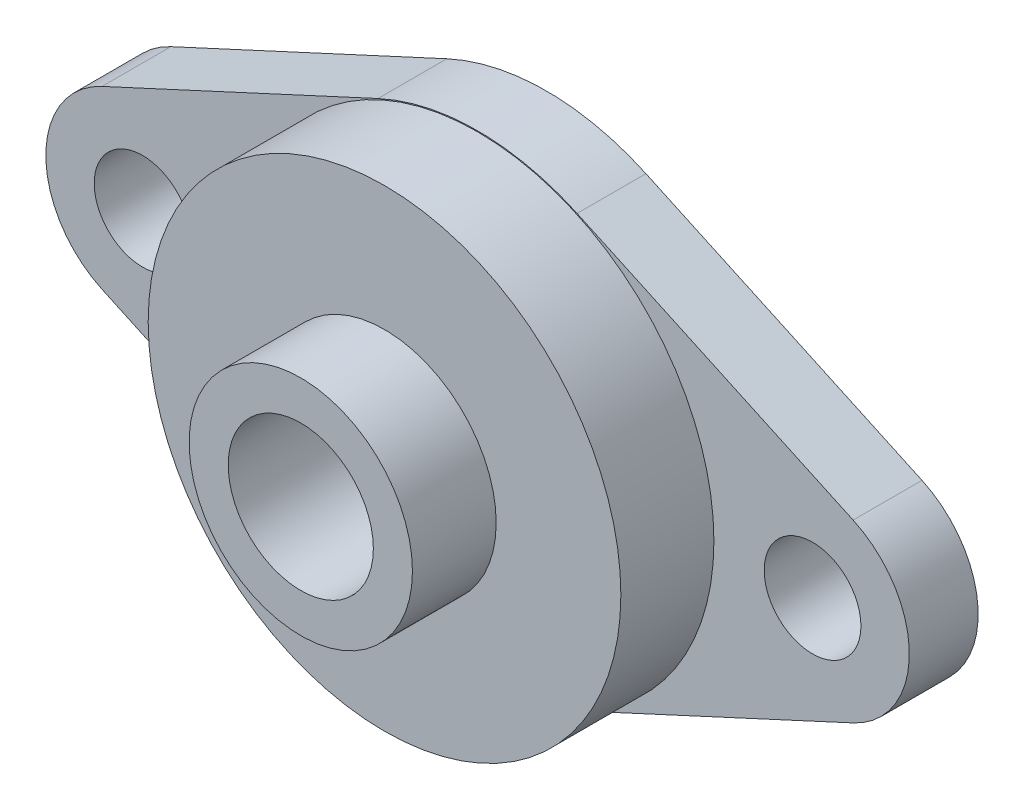
from build123d import *

# Parameters (mm, degrees)
SKETCH_2_R      = 2.6
SKETCH_2_R_2    = 3.9
EXTRUDE_1_DEPTH = 3.7
SKETCH_3_R      = 12.7
SKETCH_3_R_2    = 3.9
EXTRUDE_2_DEPTH = 5
SKETCH_4_R      = 6
SKETCH_4_R_2    = 3.9
EXTRUDE_3_DEPTH = 4.5


with BuildPart() as part:
    # 草圖2 → 填料-伸長1 (new body)
    with BuildSketch(Plane.XY):
        with BuildLine():
            Line((-20.181106134, 4.72046354), (-5.347916667, 11.574207849))
            ThreePointArc((-5.347916667, 11.574207849), (0, 12.75), (5.347916667, 11.574207849))
            Line((5.347916667, 11.574207849), (20.181106134, 4.72046354))
            ThreePointArc((20.181106134, 4.72046354), (23.2, 0), (20.181106134, -4.72046354))
            Line((20.181106134, -4.72046354), (5.347916667, -11.574207849))
            ThreePointArc((5.347916667, -11.574207849), (0, -12.75), (-5.347916667, -11.574207849))
            Line((-5.347916667, -11.574207849), (-20.181106134, -4.72046354))
            ThreePointArc((-20.181106134, -4.72046354), (-23.2, 0), (-20.181106134, 4.72046354))
        make_face()
        with Locations((-18, 0)):
            Circle(SKETCH_2_R, mode=Mode.SUBTRACT)
        with Locations((18, 0)):
            Circle(SKETCH_2_R, mode=Mode.SUBTRACT)
        Circle(SKETCH_2_R_2, mode=Mode.SUBTRACT)
    extrude(amount=EXTRUDE_1_DEPTH)

    # 草圖3 → 填料-伸長2 (add)
    with BuildSketch(Plane.XY.offset(3.7)):
        Circle(SKETCH_3_R)
        Circle(SKETCH_3_R_2, mode=Mode.SUBTRACT)
    extrude(amount=EXTRUDE_2_DEPTH)

    # 草圖4 → 填料-伸長3 (add)
    with BuildSketch(Plane.XY.offset(8.7)):
        Circle(SKETCH_4_R)
        Circle(SKETCH_4_R_2, mode=Mode.SUBTRACT)
    extrude(amount=EXTRUDE_3_DEPTH)


solid = part.part
